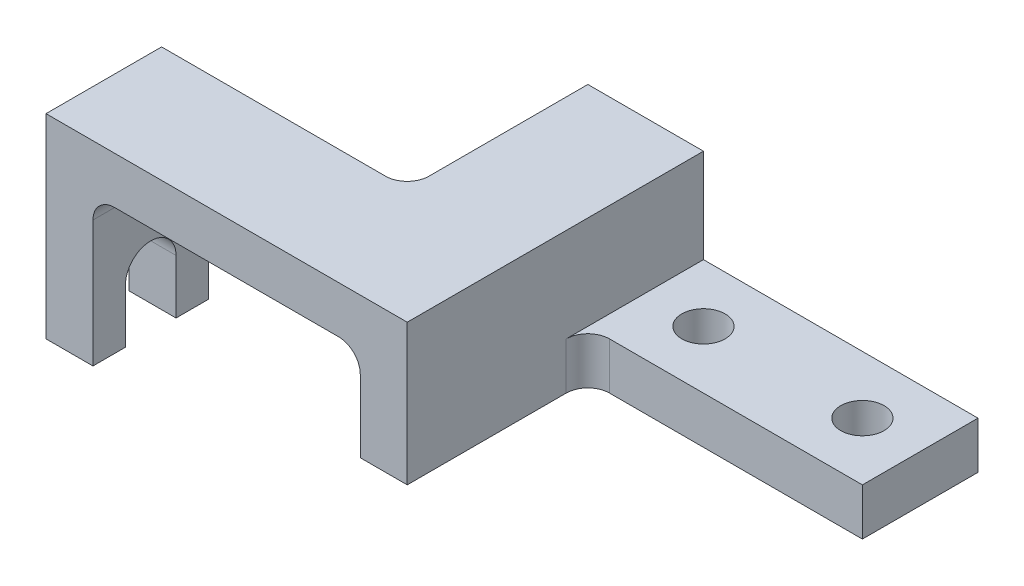
from build123d import *

# Parameters (mm, degrees)
SKETCH_1_R          = 6
EXTRUDE_1_DEPTH     = 54
FILLET_1_R          = 6
SKETCH_2_W          = 76
SKETCH_2_H          = 26
CUT_EXTRUDE_1_DEPTH = 83
CUT_EXTRUDE_2_REACH = 178


with BuildPart() as part:
    # 스케치1 → 보스-돌출1 (new body)
    with BuildSketch(Plane(origin=(0, 0, 0), x_dir=(1, 0, 0), z_dir=(0, 1, 0))):
        Polygon((0, 32), (68, 32), (68, 82), (176, 82), (176, 50), (100, 50), (100, 0), (0, 0), align=None)
        with Locations(Location((116, 66, 0), (0, 0, 270))):  # turned: the seam where the file's is
            Circle(SKETCH_1_R, mode=Mode.SUBTRACT)
        with Locations(Location((160, 66, 0), (0, 0, 270))):  # turned: the seam where the file's is
            Circle(SKETCH_1_R, mode=Mode.SUBTRACT)
    extrude(amount=EXTRUDE_1_DEPTH)

    # 필렛1
    fillet_1_edges = [part.edges().sort_by_distance(p)[0] for p in [
        (68, 27, -32),
        (100, 27, -50),
    ]]
    fillet(fillet_1_edges, radius=FILLET_1_R)

    # 스케치2 → 컷-돌출1 (cut, through all)
    with BuildSketch(Plane.XY):
        with BuildLine():
            Line((87, 35), (87, 15))
            Line((87, 15), (176, 15))
            Line((176, 15), (176, 0))
            Line((176, 0), (13, 0))
            Line((13, 0), (13, 35))
            ThreePointArc((13, 35), (14.757359313, 39.242640687), (19, 41))
            Line((19, 41), (81, 41))
            ThreePointArc((81, 41), (85.242640687, 39.242640687), (87, 35))
        make_face()
        with Locations((138, 41)):
            Rectangle(SKETCH_2_W, SKETCH_2_H)
    extrude(amount=-CUT_EXTRUDE_1_DEPTH, mode=Mode.SUBTRACT)

    # 스케치3 → 컷-돌출2 (cut, up to next)
    with BuildSketch(Plane(origin=(0, 0, 0), x_dir=(0, 0, -1), z_dir=(1, 0, 0)), mode=Mode.PRIVATE) as cut_extrude_2_sk1:
        with BuildLine():
            Line((23, 15), (23, 0))
            Line((23, 0), (9, 0))
            Line((9, 0), (9, 15))
            ThreePointArc((9, 15), (16, 22), (23, 15))
        make_face()
    cut_extrude_2_tool1 = extrude(cut_extrude_2_sk1.sketch, amount=CUT_EXTRUDE_2_REACH, mode=Mode.PRIVATE) & part.part
    add(cut_extrude_2_tool1.solids().sort_by_distance((0, 10.308437, -16))[0], mode=Mode.SUBTRACT)


solid = part.part
